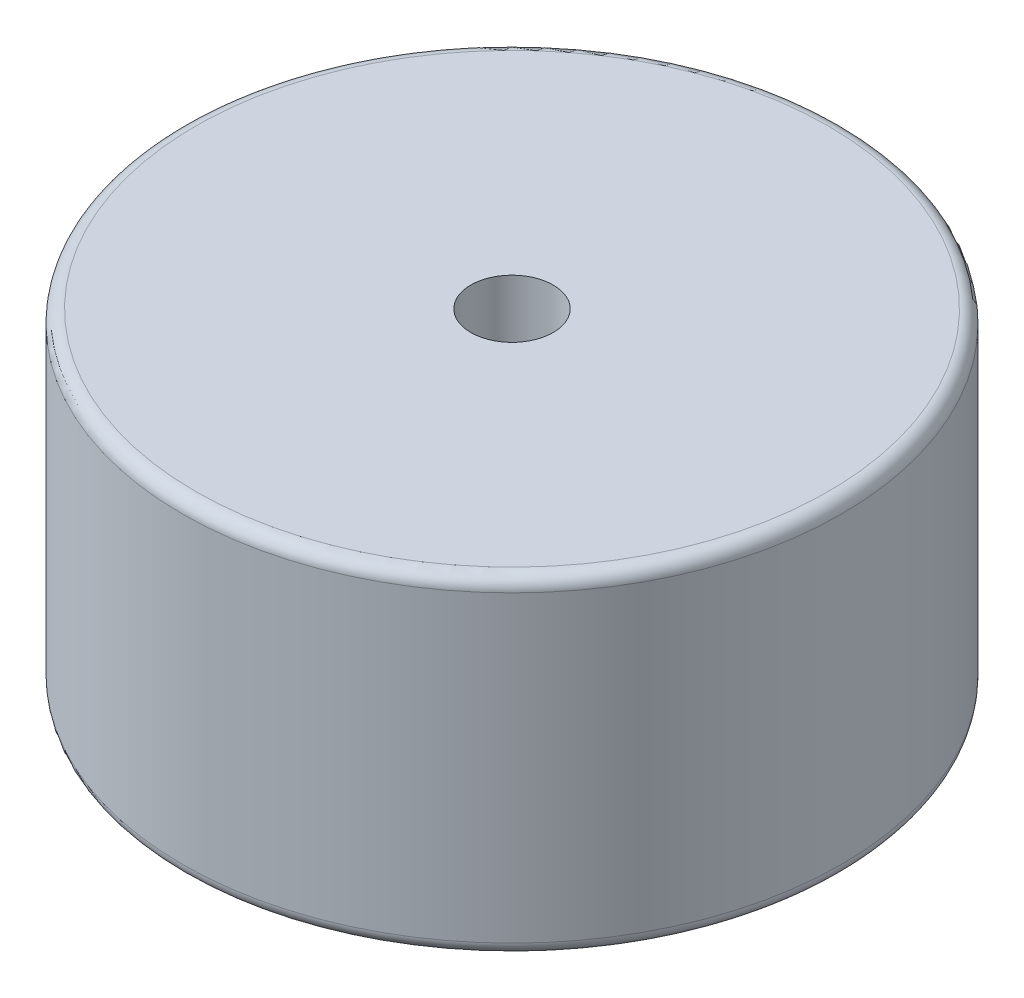
from build123d import *

# Parameters (mm, degrees)
SKETCH1_R           = 20
BOSS_EXTRUDE1_DEPTH = 20
SKETCH2_R           = 2.5
CUT_EXTRUDE1_DEPTH  = 12
FILLET1_R           = 0.79375
SKETCH3_R           = 17
SKETCH3_R_2         = 9
CUT_EXTRUDE2_DEPTH  = 0.79375


with BuildPart() as part:
    # Sketch1 → Boss-Extrude1 (new body)
    with BuildSketch(Plane(origin=(0, 0, 0), x_dir=(1, 0, 0), z_dir=(0, 1, 0))):
        Circle(SKETCH1_R)
    extrude(amount=BOSS_EXTRUDE1_DEPTH)

    # Sketch2 → Cut-Extrude1 (cut)
    with BuildSketch(Plane(origin=(0, 20, 0), x_dir=(1, 0, 0), z_dir=(0, 1, 0))):
        Circle(SKETCH2_R)
    extrude(amount=-CUT_EXTRUDE1_DEPTH, mode=Mode.SUBTRACT)

    # Fillet1
    fillet1_edges = [part.edges().sort_by_distance(p)[0] for p in [
        (-20, 0, 0),
        (-20, 20, 0),
    ]]
    fillet(fillet1_edges, radius=FILLET1_R)

    # Sketch3 → Cut-Extrude2 (cut)
    with BuildSketch(Plane.XZ):
        Circle(SKETCH3_R)
        Circle(SKETCH3_R_2, mode=Mode.SUBTRACT)
    extrude(amount=-CUT_EXTRUDE2_DEPTH, mode=Mode.SUBTRACT)


solid = part.part
